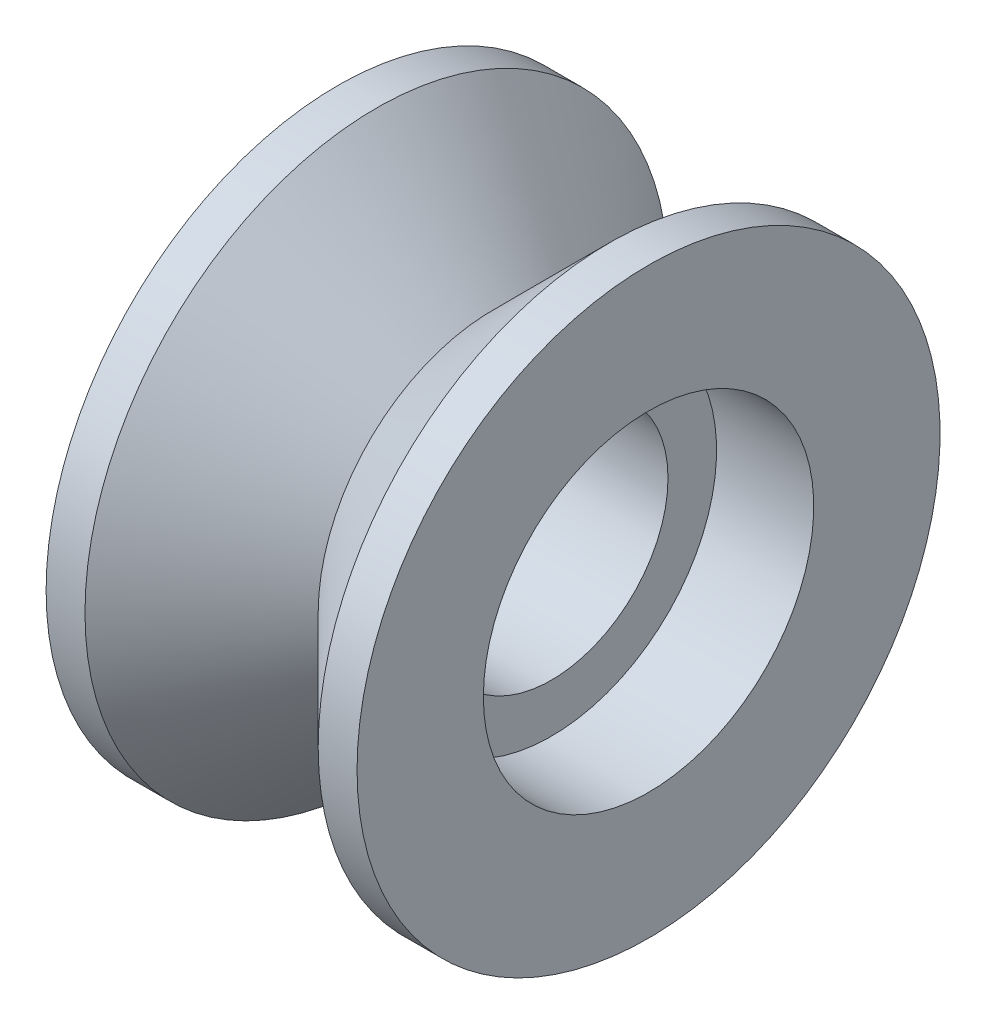
from build123d import *


with BuildPart() as part:
    # Croquis1 → Revolución1 (revolve)
    with BuildSketch(Plane.XY):
        Polygon((0, 8.5), (5, 8.5), (5, 6), (11, 6), (11, 8.5), (16, 8.5), (16, 15), (14, 15), (8, 9), (2, 15), (0, 15), align=None)
    revolve(axis=Axis((0, 0, 0), (1, 0, 0)))


solid = part.part
